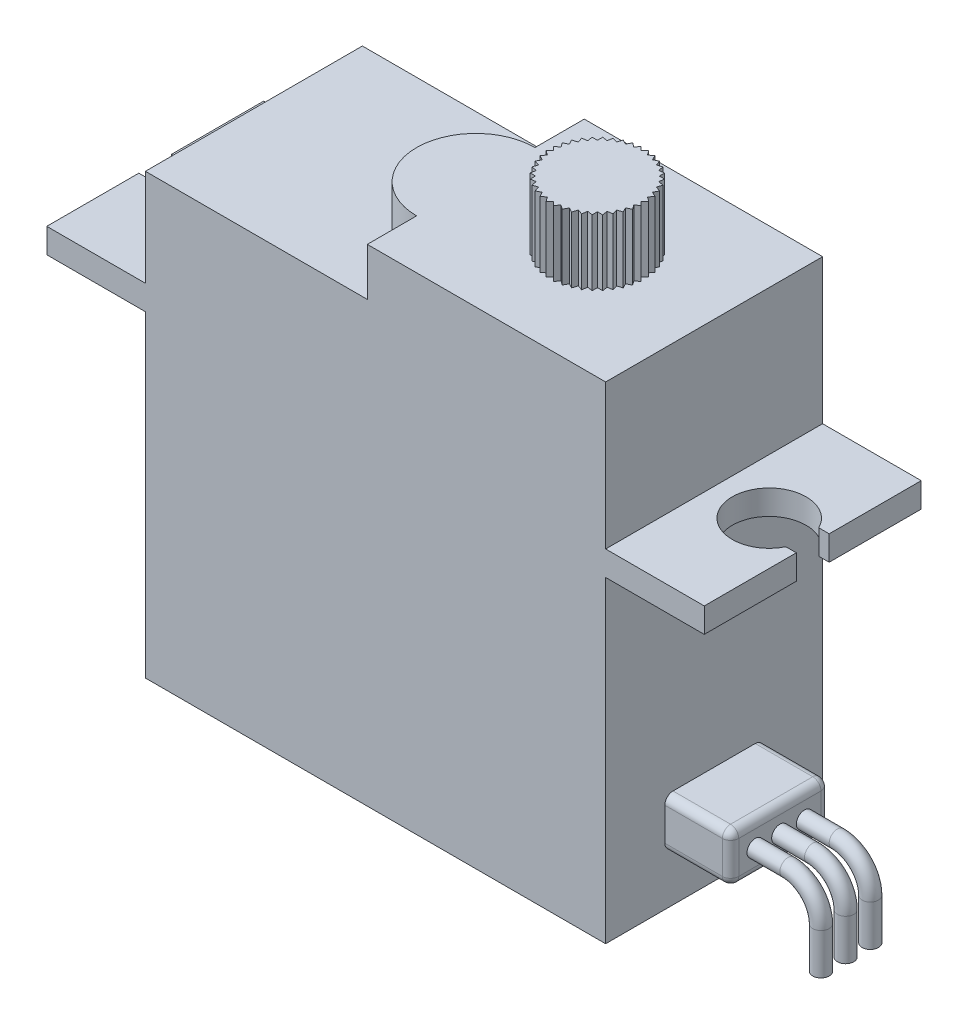
from build123d import *

# Parameters (mm, degrees)
SZKIC1_R                    = 2.9
DODANIE_WYCI_GNI_CIE1_DEPTH = 26.7
DODANIE_WYCI_GNI_CIE2_START = 19.3
DODANIE_WYCI_GNI_CIE2_DEPTH = 1.5
DODANIE_WYCI_GNI_CIE3_DEPTH = 29.6
DODANIE_WYCI_GNI_CIE4_START = 29.6
SZKIC1_5_R                  = 2.9
DODANIE_WYCI_GNI_CIE4_DEPTH = 4
WYTNIJ_WYCI_GNI_CIE1_DEPTH  = 4
SZYK_KO_OWY1_COUNT          = 40
DODANIE_WYCI_GNI_CIE5_DEPTH = 4
ZAOKR_GLENIE1_R             = 0.5
SZKIC5_R                    = 0.5


with BuildPart() as part:
    # Szkic1 → Dodanie-wyci_gni_cie1 (new body)
    with BuildSketch(Plane(origin=(0, 0, 0), x_dir=(1, 0, 0), z_dir=(0, 1, 0))):
        with BuildLine():
            Line((-20.9, 6.6), (-20.9, -6.6))
            Line((-20.9, -6.6), (-7.4, -6.6))
            Line((-7.4, -6.6), (-7.4, -3.6))
            ThreePointArc((-7.4, -3.6), (-11, 0), (-7.4, 3.6))
            Line((-7.4, 3.6), (-7.4, 6.6))
            Line((-7.4, 6.6), (-20.9, 6.6))
        make_face()
        with BuildLine():
            Line((-7.4, -3.6), (-7.4, -6.6))
            Line((-7.4, -6.6), (7.1, -6.6))
            Line((7.1, -6.6), (7.1, 6.6))
            Line((7.1, 6.6), (-7.4, 6.6))
            Line((-7.4, 6.6), (-7.4, 3.6))
            ThreePointArc((-7.4, 3.6), (-11, 0), (-7.4, -3.6))
        make_face()
        Circle(SZKIC1_R, mode=Mode.SUBTRACT)
        Circle(SZKIC1_R)
    extrude(amount=DODANIE_WYCI_GNI_CIE1_DEPTH)

    # Szkic1_3 → Dodanie-wyci_gni_cie2 (add)
    with BuildSketch(Plane(origin=(0, 0, 0), x_dir=(1, 0, 0), z_dir=(0, 1, 0)).offset(DODANIE_WYCI_GNI_CIE2_START)):
        with BuildLine():
            Line((7.1, 6.6), (7.1, -6.6))
            Line((7.1, -6.6), (13.1, -6.6))
            Line((13.1, -6.6), (13.1, -1))
            Line((13.1, -1), (12.465564437, -1))
            ThreePointArc((12.465564437, -1), (8.2, 0), (12.465564437, 1))
            Line((12.465564437, 1), (13.1, 1))
            Line((13.1, 1), (13.1, 6.6))
            Line((13.1, 6.6), (7.1, 6.6))
        make_face()
        with BuildLine():
            Line((-26.9, -6.6), (-20.9, -6.6))
            Line((-20.9, -6.6), (-20.9, 6.6))
            Line((-20.9, 6.6), (-26.9, 6.6))
            Line((-26.9, 6.6), (-26.9, 1))
            Line((-26.9, 1), (-26.265564437, 1))
            ThreePointArc((-26.265564437, 1), (-22, 0), (-26.265564437, -1))
            Line((-26.265564437, -1), (-26.9, -1))
            Line((-26.9, -1), (-26.9, -6.6))
        make_face()
    extrude(amount=DODANIE_WYCI_GNI_CIE2_DEPTH)

    # Szkic1_4 → Dodanie-wyci_gni_cie3 (add)
    with BuildSketch(Plane(origin=(0, 0, 0), x_dir=(1, 0, 0), z_dir=(0, 1, 0))):
        with BuildLine():
            Line((-7.4, -3.6), (-7.4, -6.6))
            Line((-7.4, -6.6), (7.1, -6.6))
            Line((7.1, -6.6), (7.1, 6.6))
            Line((7.1, 6.6), (-7.4, 6.6))
            Line((-7.4, 6.6), (-7.4, 3.6))
            ThreePointArc((-7.4, 3.6), (-11, 0), (-7.4, -3.6))
        make_face()
    extrude(amount=DODANIE_WYCI_GNI_CIE3_DEPTH)

    # Szkic1_5 → Dodanie-wyci_gni_cie4 (add)
    with BuildSketch(Plane(origin=(0, 0, 0), x_dir=(1, 0, 0), z_dir=(0, 1, 0)).offset(DODANIE_WYCI_GNI_CIE4_START)):
        with Locations(Location((0, 0, 0), (0, 0, 270))):
            Circle(SZKIC1_5_R)
    extrude(amount=DODANIE_WYCI_GNI_CIE4_DEPTH)

    # Szkic3 → Wytnij-wyci_gni_cie1 (cut)
    with BuildSketch(Plane(origin=(0, 33.6, 0), x_dir=(1, 0, 0), z_dir=(0, 1, 0))):
        Polygon((-0.227531378, 2.891060268), (0, 2.66352889), (0.227531378, 2.891060268), (0.227531378, 3.66352889), (-0.227531378, 3.66352889), align=None)
    wytnij_wyci_gni_cie1 = extrude(amount=-WYTNIJ_WYCI_GNI_CIE1_DEPTH, mode=Mode.SUBTRACT)

    # Szyk ko_owy1: Wytnij-wyci_gni_cie1 ×40 about axis
    szyk_ko_owy1_axis = Axis((0, 0, 0), (0, 1, 0))
    for i in range(1, SZYK_KO_OWY1_COUNT):
        add(wytnij_wyci_gni_cie1.rotate(szyk_ko_owy1_axis, i * 360 / SZYK_KO_OWY1_COUNT), mode=Mode.SUBTRACT)

    # Szkic4 → Dodanie-wyci_gni_cie5 (add)
    with BuildSketch(Plane(origin=(7.1, 0, 0), x_dir=(0, 0, -1), z_dir=(1, 0, 0))):
        with BuildLine():
            Line((-2.5, 3), (2.5, 3))
            ThreePointArc((2.5, 3), (2.853553391, 3.146446609), (3, 3.5))
            Line((3, 3.5), (3, 5.5))
            ThreePointArc((3, 5.5), (2.853553391, 5.853553391), (2.5, 6))
            Line((2.5, 6), (-2.5, 6))
            ThreePointArc((-2.5, 6), (-2.853553391, 5.853553391), (-3, 5.5))
            Line((-3, 5.5), (-3, 3.5))
            ThreePointArc((-3, 3.5), (-2.853553391, 3.146446609), (-2.5, 3))
        make_face()
    extrude(amount=DODANIE_WYCI_GNI_CIE5_DEPTH)

    # Zaokr_glenie1
    zaokr_glenie1_edges = [part.edges().sort_by_distance(p)[0] for p in [
        (11.1, 5.853553391, -2.853553391),
        (11.1, 6, 0),
        (11.1, 5.853553391, 2.853553391),
        (11.1, 4.5, 3),
        (11.1, 3.146446609, 2.853553391),
        (11.1, 3, 0),
        (11.1, 3.146446609, -2.853553391),
        (11.1, 4.5, -3),
    ]]
    fillet(zaokr_glenie1_edges, radius=ZAOKR_GLENIE1_R)

    # Wyci_gni_cie po _cie_ce1: sweep along a path in Szkic6
    with BuildLine(Plane.XY) as wyci_gni_cie_po_cie_ce1_path:
        Line((11.1, 4.5), (13.1, 4.5))
        ThreePointArc((13.1, 4.5), (14.514213562, 3.914213562), (15.1, 2.5))
        Line((15.1, 2.5), (15.1, 0))
    # Szkic5 → Wyci_gni_cie po _cie_ce1 (sweep)
    with BuildSketch(Plane(origin=(11.1, 0, 0), x_dir=(0, 0, -1), z_dir=(1, 0, 0))):
        with Locations((-1.5, 4.5)):
            Circle(SZKIC5_R)
        with Locations((0, 4.5)):
            Circle(SZKIC5_R)
        with Locations((1.5, 4.5)):
            Circle(SZKIC5_R)
    sweep(path=wyci_gni_cie_po_cie_ce1_path.line)


solid = part.part
